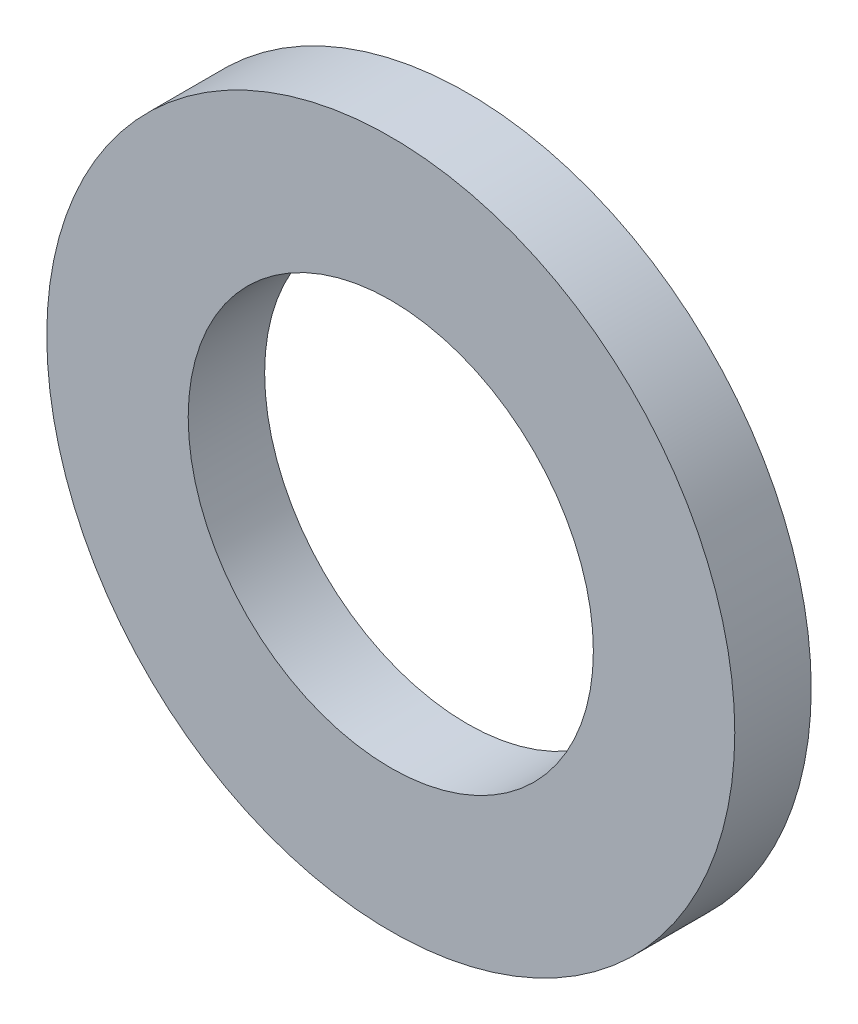
from build123d import *

# Parameters (mm, degrees)
SKETCH_1_R      = 4.5
SKETCH_1_R_2    = 2.65
EXTRUDE_1_DEPTH = 1


with BuildPart() as part:
    # Эскиз1 → Бобышка-Вытянуть1 (new body)
    with BuildSketch(Plane.XY):
        Circle(SKETCH_1_R)
        Circle(SKETCH_1_R_2, mode=Mode.SUBTRACT)
    extrude(amount=EXTRUDE_1_DEPTH)


solid = part.part
